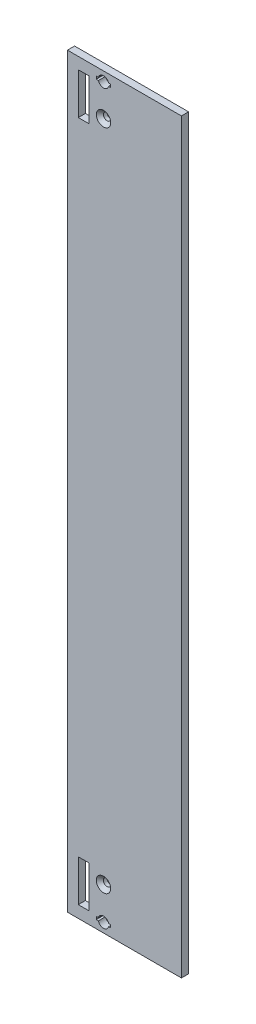
from build123d import *

# Parameters (mm, degrees)
SKETCH1_W           = 40
SKETCH1_H           = 262
SKETCH1_R           = 1.28
SKETCH1_W_2         = 3.8
SKETCH1_H_2         = 14.55
BOSS_EXTRUDE1_DEPTH = 2.5
CHAMFER1_SIZE       = 1.25
CHAMFER2_SIZE       = 1.25


with BuildPart() as part:
    # Sketch1 → Boss-Extrude1 (new body)
    with BuildSketch(Plane.XY):
        with Locations((20, 131)):
            Rectangle(SKETCH1_W, SKETCH1_H)
        with Locations((12.65, 247.5)):
            Circle(SKETCH1_R, mode=Mode.SUBTRACT)
        with Locations((12.65, 14.75)):
            Circle(SKETCH1_R, mode=Mode.SUBTRACT)
        with Locations((5.7, 250.675)):
            Rectangle(SKETCH1_W_2, SKETCH1_H_2, mode=Mode.SUBTRACT)
        with Locations((5.7, 11.475)):
            Rectangle(SKETCH1_W_2, SKETCH1_H_2, mode=Mode.SUBTRACT)
        with BuildLine():
            Line((10.858464346, 3.8), (10.108464346, 3.8))
            Line((10.108464346, 3.8), (10.108464346, 2.8))
            Line((10.108464346, 2.8), (10.858464346, 2.8))
            ThreePointArc((10.858464346, 2.8), (12.65, 1.44), (14.441535654, 2.8))
            Line((14.441535654, 2.8), (15.191535654, 2.8))
            Line((15.191535654, 2.8), (15.191535654, 3.8))
            Line((15.191535654, 3.8), (14.441535654, 3.8))
            ThreePointArc((14.441535654, 3.8), (12.65, 5.16), (10.858464346, 3.8))
        make_face(mode=Mode.SUBTRACT)
        with BuildLine():
            Line((10.858464346, 259.2), (10.108464346, 259.2))
            Line((10.108464346, 259.2), (10.108464346, 258.2))
            Line((10.108464346, 258.2), (10.858464346, 258.2))
            ThreePointArc((10.858464346, 258.2), (12.65, 256.84), (14.441535654, 258.2))
            Line((14.441535654, 258.2), (15.191535654, 258.2))
            Line((15.191535654, 258.2), (15.191535654, 259.2))
            Line((15.191535654, 259.2), (14.441535654, 259.2))
            ThreePointArc((14.441535654, 259.2), (12.65, 260.56), (10.858464346, 259.2))
        make_face(mode=Mode.SUBTRACT)
    extrude(amount=BOSS_EXTRUDE1_DEPTH)

    # Chamfer1
    chamfer1_edges = [part.edges().sort_by_distance(p)[0] for p in [
        (11.37, 247.5, 2.5),
    ]]
    chamfer(chamfer1_edges, length=CHAMFER1_SIZE)

    # Chamfer2
    chamfer2_edges = [part.edges().sort_by_distance(p)[0] for p in [
        (11.37, 14.75, 2.5),
    ]]
    chamfer(chamfer2_edges, length=CHAMFER2_SIZE)


solid = part.part
